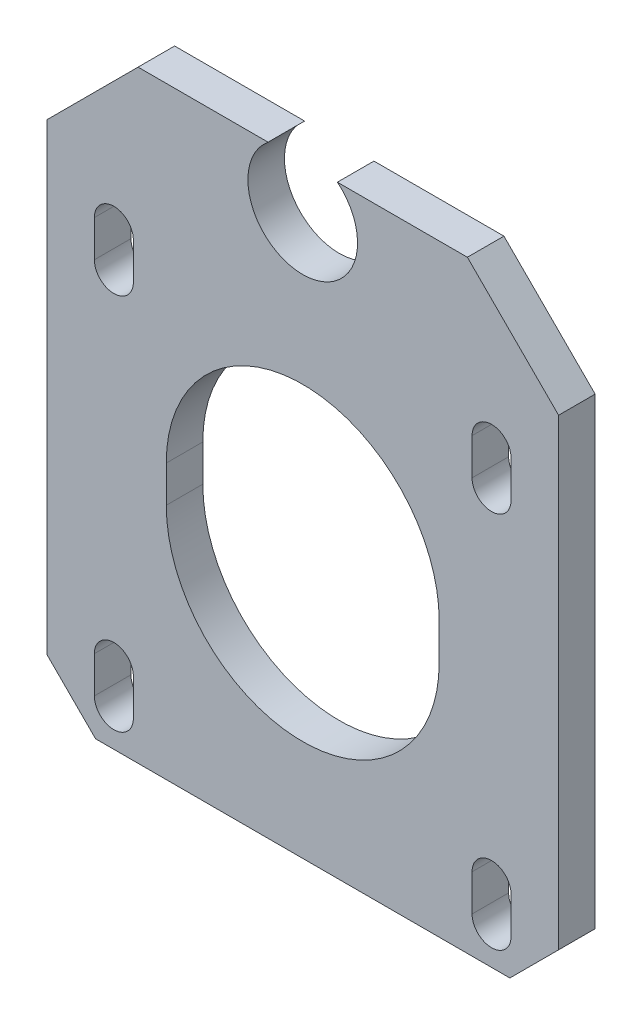
from build123d import *

# Parameters (mm, degrees)
BOSS_EXTRUDE1_DEPTH = 3
CHAMFER1_SIZE       = 4


with BuildPart() as part:
    # Sketch1 → Boss-Extrude1 (new body)
    with BuildSketch(Plane.XY):
        with BuildLine():
            Line((-21, -21), (21, -21))
            Line((21, -21), (21, 21))
            Line((21, 21), (13.513592999, 28.486407001))
            Line((13.513592999, 28.486407001), (2.845165412, 28.486407001))
            ThreePointArc((2.845165412, 28.486407001), (0, 20.5), (-2.845165412, 28.486407001))
            Line((-2.845165412, 28.486407001), (-13.513592999, 28.486407001))
            Line((-13.513592999, 28.486407001), (-21, 21))
            Line((-21, 21), (-21, -21))
        make_face()
        with BuildLine():
            Line((-11.2, 1.5), (-11.2, -1.5))
            ThreePointArc((-11.2, -1.5), (0, -12.7), (11.2, -1.5))
            Line((11.2, -1.5), (11.2, 1.5))
            ThreePointArc((11.2, 1.5), (0, 12.7), (-11.2, 1.5))
        make_face(mode=Mode.SUBTRACT)
        with BuildLine():
            Line((-13.9, -15), (-13.9, -18))
            ThreePointArc((-13.9, -18), (-15.5, -19.6), (-17.1, -18))
            Line((-17.1, -18), (-17.1, -15))
            ThreePointArc((-17.1, -15), (-15.5, -13.4), (-13.9, -15))
        make_face(mode=Mode.SUBTRACT)
        with BuildLine():
            Line((-13.9, 16), (-13.9, 13))
            ThreePointArc((-13.9, 13), (-15.5, 11.4), (-17.1, 13))
            Line((-17.1, 13), (-17.1, 16))
            ThreePointArc((-17.1, 16), (-15.5, 17.6), (-13.9, 16))
        make_face(mode=Mode.SUBTRACT)
        with BuildLine():
            Line((13.9, -15), (13.9, -18))
            ThreePointArc((13.9, -18), (15.5, -19.6), (17.1, -18))
            Line((17.1, -18), (17.1, -15))
            ThreePointArc((17.1, -15), (15.5, -13.4), (13.9, -15))
        make_face(mode=Mode.SUBTRACT)
        with BuildLine():
            Line((13.9, 16), (13.9, 13))
            ThreePointArc((13.9, 13), (15.5, 11.4), (17.1, 13))
            Line((17.1, 13), (17.1, 16))
            ThreePointArc((17.1, 16), (15.5, 17.6), (13.9, 16))
        make_face(mode=Mode.SUBTRACT)
    extrude(amount=BOSS_EXTRUDE1_DEPTH)

    # Chamfer1
    chamfer1_edges = [part.edges().sort_by_distance(p)[0] for p in [
        (21, -21, 1.5),
        (-21, -21, 1.5),
    ]]
    chamfer(chamfer1_edges, length=CHAMFER1_SIZE)


solid = part.part
